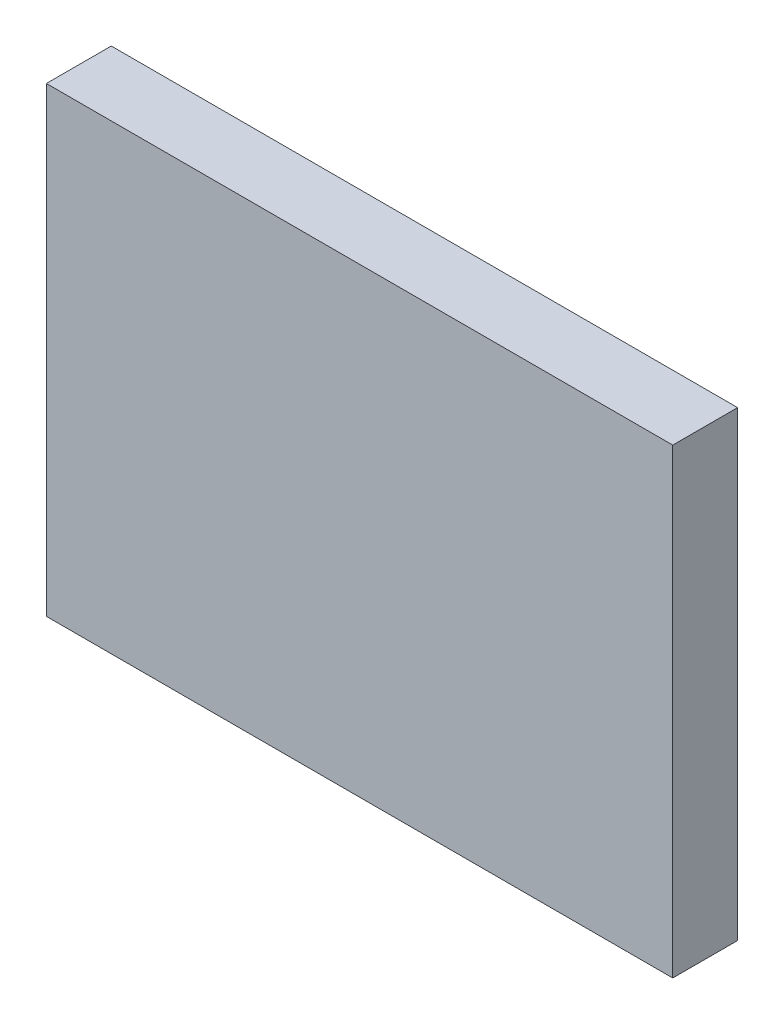
from build123d import *

# Parameters (mm, degrees)
SKETCH1_W               = 9.652
SKETCH1_H               = 7.112
COMPONENT_OUTLINE_DEPTH = 1


with BuildPart() as part:
    # Sketch1 → Component_Outline (new body)
    with BuildSketch(Plane.XY):
        Rectangle(SKETCH1_W, SKETCH1_H)
    extrude(amount=COMPONENT_OUTLINE_DEPTH)


solid = part.part
